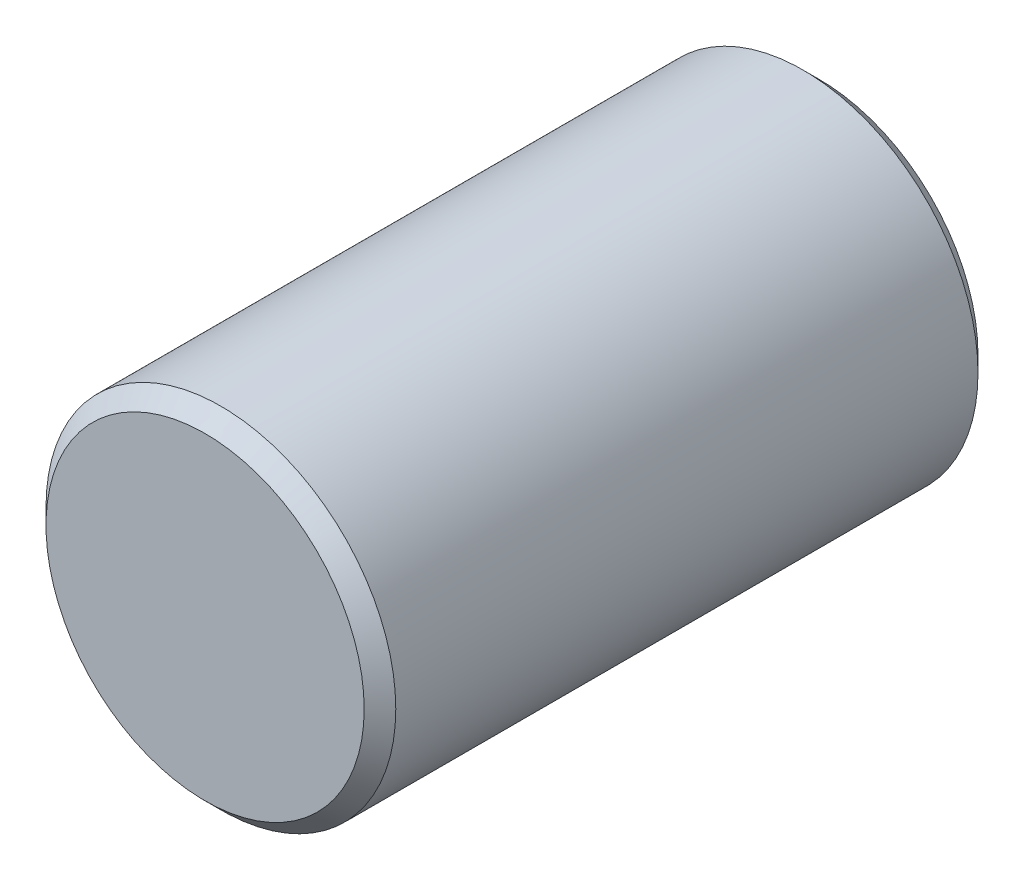
from build123d import *

# Parameters (mm, degrees)
SKETCH1_R           = 3.875
BOSS_EXTRUDE1_DEPTH = 13.6
CHAMFER1_SIZE       = 0.35


with BuildPart() as part:
    # Sketch1 → Boss-Extrude1 (new body)
    with BuildSketch(Plane.XY):
        Circle(SKETCH1_R)
    extrude(amount=BOSS_EXTRUDE1_DEPTH)

    # Chamfer1
    chamfer1_edges = [part.edges().sort_by_distance(p)[0] for p in [
        (-3.875, 0, 0),
        (-3.875, 0, 13.6),
    ]]
    chamfer(chamfer1_edges, length=CHAMFER1_SIZE)


solid = part.part
